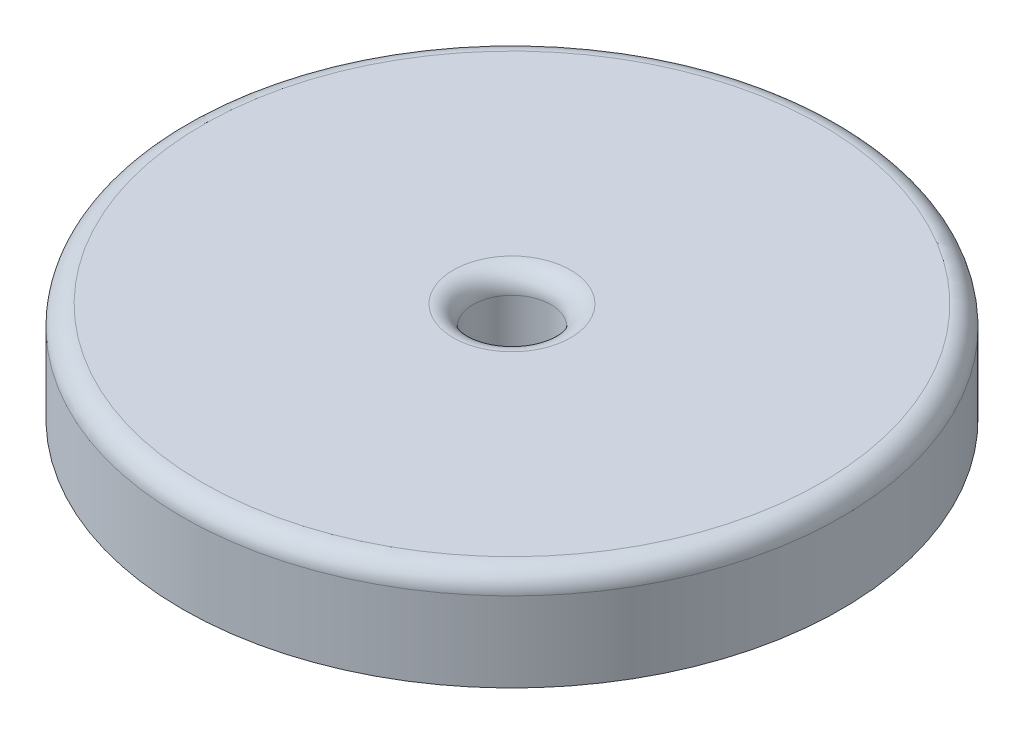
from build123d import *

# Parameters (mm, degrees)
SKETCH1_R           = 33.072163115
BOSS_EXTRUDE1_DEPTH = 10
SKETCH2_R           = 3.89
CUT_EXTRUDE1_DEPTH  = 8
SKETCH3_R           = 1.935
CUT_EXTRUDE2_DEPTH  = 8
FILLET1_R           = 2
FILLET2_R           = 2


with BuildPart() as part:
    # Sketch1 → Boss-Extrude1 (new body)
    with BuildSketch(Plane(origin=(0, 0, 0), x_dir=(1, 0, 0), z_dir=(0, 1, 0))):
        Circle(SKETCH1_R)
    extrude(amount=BOSS_EXTRUDE1_DEPTH)

    # Sketch2 → Cut-Extrude1 (cut)
    with BuildSketch(Plane(origin=(0, 10, 0), x_dir=(1, 0, 0), z_dir=(0, 1, 0))):
        Circle(SKETCH2_R)
    extrude(amount=-CUT_EXTRUDE1_DEPTH, mode=Mode.SUBTRACT)

    # Sketch3 → Cut-Extrude2 (cut)
    with BuildSketch(Plane(origin=(0, 2, 0), x_dir=(1, 0, 0), z_dir=(0, 1, 0))):
        Circle(SKETCH3_R)
    extrude(amount=-CUT_EXTRUDE2_DEPTH, mode=Mode.SUBTRACT)

    # Fillet1
    fillet1_edges = [part.edges().sort_by_distance(p)[0] for p in [
        (-33.072163115, 10, 0),
    ]]
    fillet(fillet1_edges, radius=FILLET1_R)

    # Fillet2
    fillet2_edges = [part.edges().sort_by_distance(p)[0] for p in [
        (-3.89, 10, 0),
    ]]
    fillet(fillet2_edges, radius=FILLET2_R)


solid = part.part
